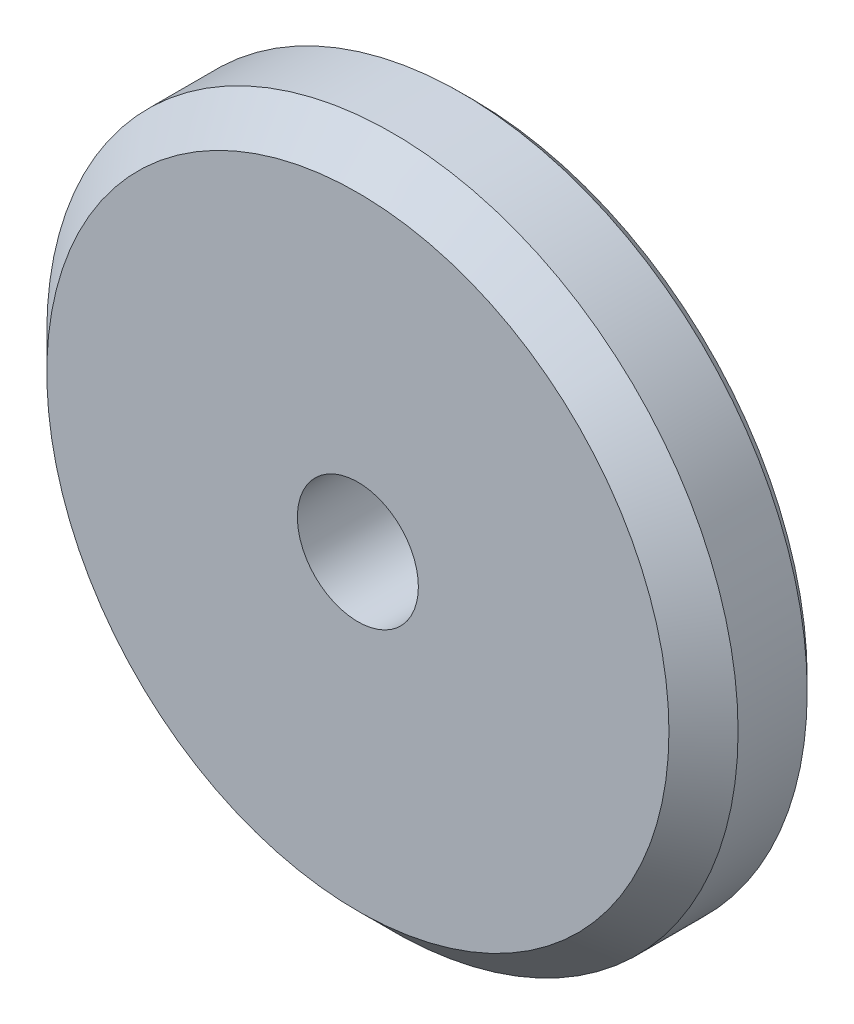
from build123d import *

# Parameters (mm, degrees)
SKETCH_2_R      = 30
SKETCH_2_R_2    = 5.25
EXTRUDE_1_DEPTH = 10
CHAMFER_1_SIZE  = 3
CHAMFER_2_SIZE  = 1


with BuildPart() as part:
    # Эскиз2 → Бобышка-Вытянуть1 (new body)
    with BuildSketch(Plane.XY):
        Circle(SKETCH_2_R)
        Circle(SKETCH_2_R_2, mode=Mode.SUBTRACT)
    extrude(amount=EXTRUDE_1_DEPTH)

    # Фаска1
    chamfer_1_edges = [part.edges().sort_by_distance(p)[0] for p in [
        (-30, 0, 10),
    ]]
    chamfer(chamfer_1_edges, length=CHAMFER_1_SIZE)

    # Фаска2
    chamfer_2_edges = [part.edges().sort_by_distance(p)[0] for p in [
        (-30, 0, 0),
    ]]
    chamfer(chamfer_2_edges, length=CHAMFER_2_SIZE)


solid = part.part
